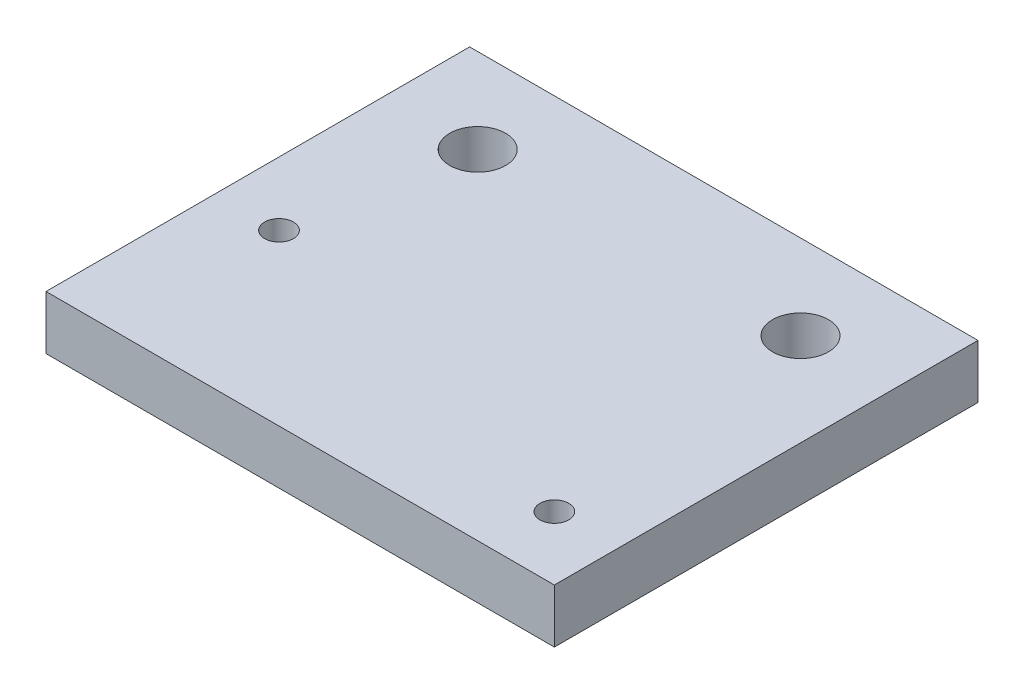
from build123d import *

# Parameters (mm, degrees)
SKETCH1_W           = 60
SKETCH1_H           = 50
SKETCH1_R           = 3.3
SKETCH1_R_2         = 1.7
BOSS_EXTRUDE1_DEPTH = 6.35


with BuildPart() as part:
    # Sketch1 → Boss-Extrude1 (new body)
    with BuildSketch(Plane(origin=(0, 0, 0), x_dir=(1, 0, 0), z_dir=(0, 1, 0))):
        with Locations((30, 25)):
            Rectangle(SKETCH1_W, SKETCH1_H)
        with Locations((10.95, 40)):
            Circle(SKETCH1_R, mode=Mode.SUBTRACT)
        with Locations((49.05, 40)):
            Circle(SKETCH1_R, mode=Mode.SUBTRACT)
        with Locations((7.5, 20)):
            Circle(SKETCH1_R_2, mode=Mode.SUBTRACT)
        with Locations((52.5, 7.5)):
            Circle(SKETCH1_R_2, mode=Mode.SUBTRACT)
    extrude(amount=BOSS_EXTRUDE1_DEPTH)


solid = part.part
